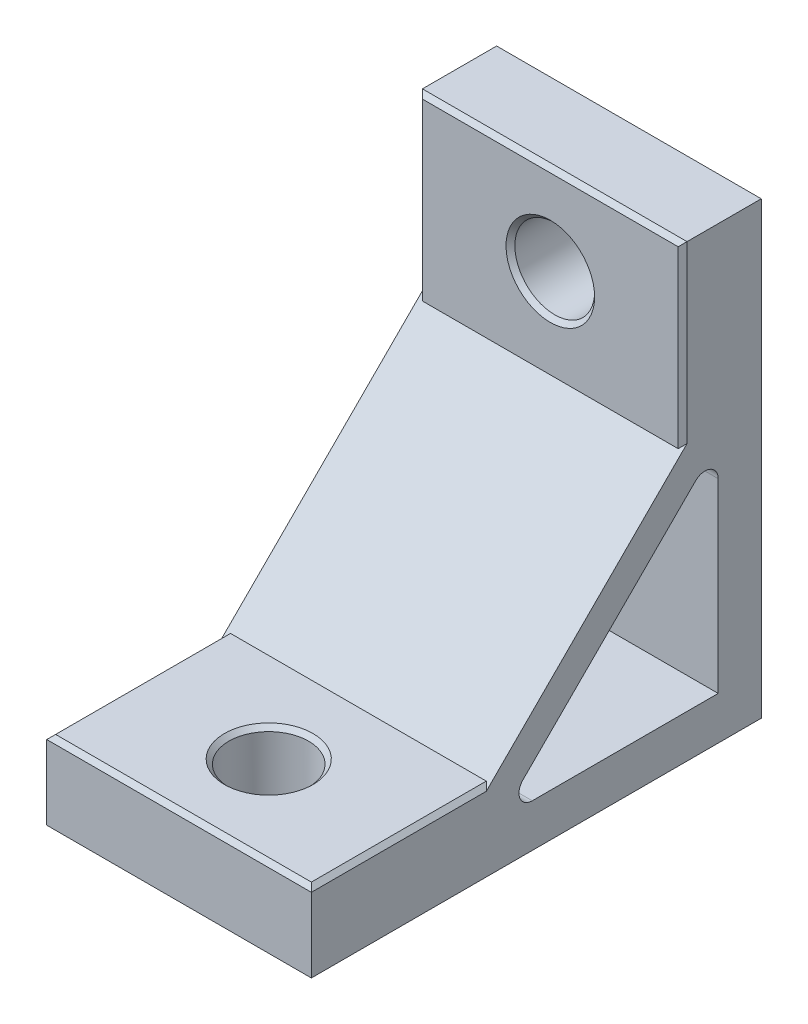
from build123d import *

# Parameters (mm, degrees)
BOSS_EXTRUDE1_DEPTH     = 14.94
CUT_EXTRUDE1_DEPTH      = 15.94
CUT_EXTRUDE1_DEPTH_BACK = 15.94
FILLET1_R               = 1.5
F_1_0MM_DOWEL_HOLE1_D   = 9
F_1_0MM_DOWEL_HOLE2_D   = 9
CHAMFER1_SIZE           = 0.5


with BuildPart() as part:
    # Sketch1 → Boss-Extrude1 (new body, symmetric)
    with BuildSketch(Plane(origin=(0, 0, 0), x_dir=(0, 0, -1), z_dir=(1, 0, 0))):
        Polygon((-21.67, 0), (-41.92, 0), (-41.92, -8.88), (8.88, -8.88), (8.88, 41.92), (0, 41.92), (0, 21.67), align=None)
    extrude(amount=BOSS_EXTRUDE1_DEPTH, both=True)

    # Sketch2 → Cut-Extrude1 (cut, two sides)
    with BuildSketch(Plane(origin=(0, 0, 0), x_dir=(0, 0, -1), z_dir=(1, 0, 0))) as cut_extrude1_sk:
        Polygon((-20.598831175, -4.02), (4.02, 20.598831175), (4.02, -4.02), align=None)
    extrude(amount=CUT_EXTRUDE1_DEPTH, mode=Mode.SUBTRACT)
    extrude(cut_extrude1_sk.sketch, amount=-CUT_EXTRUDE1_DEPTH_BACK, mode=Mode.SUBTRACT)

    # Fillet1
    fillet1_edges = [part.edges().sort_by_distance(p)[0] for p in [
        (0, -4.02, 20.598831175),
        (0, 20.598831175, -4.02),
    ]]
    fillet(fillet1_edges, radius=FILLET1_R)

    # Ø1.0mm Dowel Hole1 (through all)
    with Locations(Plane(origin=(0, 0, 0), x_dir=(1, 0, 0), z_dir=(0, 1, 0))):
        with Locations((0, -31.795)):
            Hole(F_1_0MM_DOWEL_HOLE1_D / 2)

    # Ø1.0mm Dowel Hole2 (through all)
    with Locations(Plane.XY):
        with Locations((0, 31.795)):
            Hole(F_1_0MM_DOWEL_HOLE2_D / 2)

    # Chamfer1
    chamfer1_edges = [part.edges().sort_by_distance(p)[0] for p in [
        (0, 0, 41.92),
        (0, 41.92, 0),
        (14.94, 31.795, 0),
        (14.94, 0, 31.795),
        (4.5, 0, 31.795),
        (4.5, 31.795, 0),
        (-14.94, 0, 31.795),
        (-14.94, 31.795, 0),
    ]]
    chamfer(chamfer1_edges, length=CHAMFER1_SIZE)


solid = part.part
